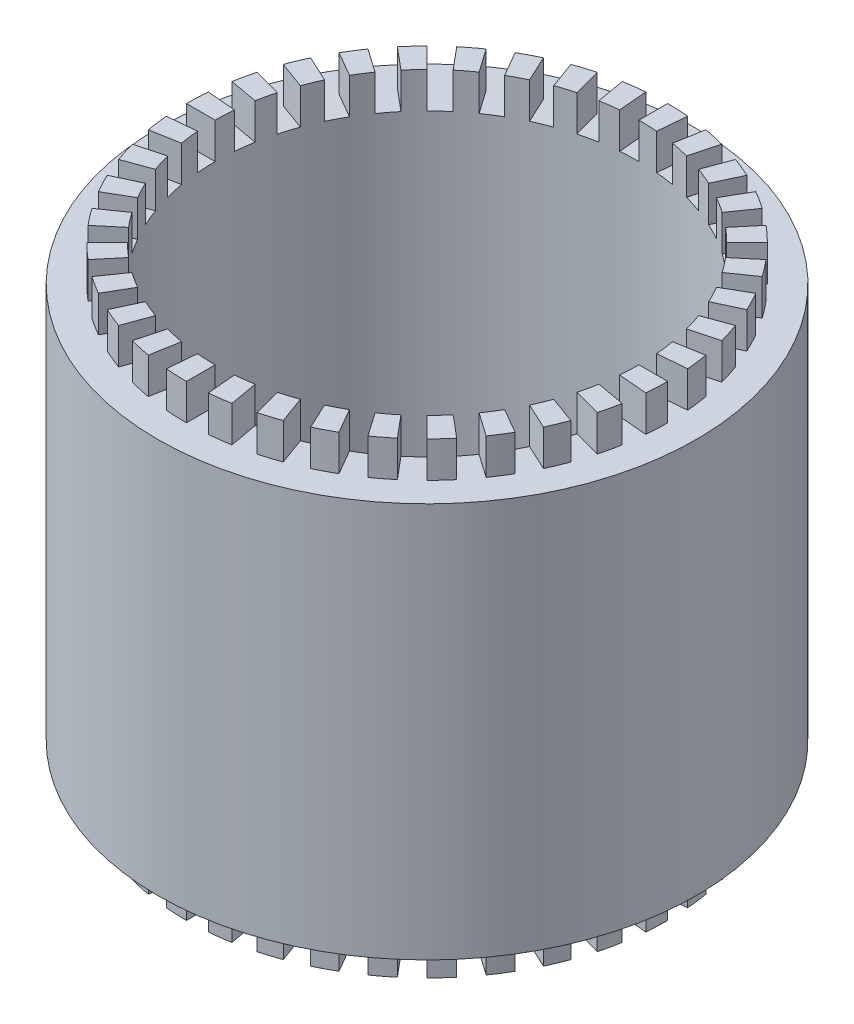
from build123d import *

# Parameters (mm, degrees)
SKETCH1_R           = 37.5
SKETCH1_R_2         = 29.5
BOSS_EXTRUDE1_DEPTH = 55
SKETCH2_R           = 33.5
SKETCH2_R_2         = 29.5
BOSS_EXTRUDE2_DEPTH = 5
SKETCH3_R           = 33.5
SKETCH3_R_2         = 29.5
BOSS_EXTRUDE3_DEPTH = 5
CUT_EXTRUDE1_DEPTH  = 5
CUT_EXTRUDE2_DEPTH  = 5


with BuildPart() as part:
    # Sketch1 → Boss-Extrude1 (new body)
    with BuildSketch(Plane(origin=(0, 0, 0), x_dir=(1, 0, 0), z_dir=(0, 1, 0))):
        Circle(SKETCH1_R)
        Circle(SKETCH1_R_2, mode=Mode.SUBTRACT)
    extrude(amount=BOSS_EXTRUDE1_DEPTH)

    # Sketch2 → Boss-Extrude2 (add)
    with BuildSketch(Plane(origin=(0, 55, 0), x_dir=(1, 0, 0), z_dir=(0, 1, 0))):
        Circle(SKETCH2_R)
        Circle(SKETCH2_R_2, mode=Mode.SUBTRACT)
    extrude(amount=BOSS_EXTRUDE2_DEPTH)

    # Sketch3 → Boss-Extrude3 (add)
    with BuildSketch(Plane.XZ):
        Circle(SKETCH3_R)
        Circle(SKETCH3_R_2, mode=Mode.SUBTRACT)
    extrude(amount=BOSS_EXTRUDE3_DEPTH)

    # Sketch4 → Cut-Extrude1 (cut)
    with BuildSketch(Plane.XZ.offset(5)):
        with BuildLine():
            Line((0, 29.5), (0, 33.5))
            ThreePointArc((0, 33.5), (1.461249477, 33.468115423), (2.919717382, 33.372522386))
            Line((2.919717382, 33.372522386), (2.571094411, 29.387743594))
            ThreePointArc((2.571094411, 29.387743594), (1.286771927, 29.471922537), (0, 29.5))
        make_face()
        with BuildLine():
            Line((5.122621241, 29.051828714), (5.817213952, 32.991059726))
            ThreePointArc((5.817213952, 32.991059726), (7.250727067, 32.705916239), (8.670438011, 32.358515181))
            Line((8.670438011, 32.358515181), (7.635161831, 28.494811876))
            ThreePointArc((7.635161831, 28.494811876), (6.384968611, 28.80073221), (5.122621241, 29.051828714))
        make_face()
        with BuildLine():
            Line((10.089594228, 27.720932313), (11.457674801, 31.479702796))
            ThreePointArc((11.457674801, 31.479702796), (12.819894984, 30.949964339), (14.157711768, 30.361310866))
            Line((14.157711768, 30.361310866), (12.467238721, 26.736079718))
            ThreePointArc((12.467238721, 26.736079718), (11.289161255, 27.254446209), (10.089594228, 27.720932313))
        make_face()
        with BuildLine():
            Line((14.75, 25.547749412), (16.75, 29.011851027))
            ThreePointArc((16.75, 29.011851027), (17.99953688, 28.253613435), (19.214810618, 27.441593484))
            Line((19.214810618, 27.441593484), (16.920504872, 24.164985307))
            ThreePointArc((16.920504872, 24.164985307), (15.850338446, 24.880047651), (14.75, 25.547749412))
        make_face()
        with BuildLine():
            Line((18.962234486, 22.598311072), (21.533384924, 25.662488844))
            ThreePointArc((21.533384924, 25.662488844), (22.632271955, 24.698790783), (23.68807717, 23.68807717))
            Line((23.68807717, 23.68807717), (20.859650045, 20.859650045))
            ThreePointArc((20.859650045, 20.859650045), (19.929911125, 21.749681436), (18.962234486, 22.598311072))
        make_face()
        with BuildLine():
            Line((22.598311072, 18.962234486), (25.662488844, 21.533384924))
            ThreePointArc((25.662488844, 21.533384924), (26.5773369, 20.393507872), (27.441593484, 19.214810618))
            Line((27.441593484, 19.214810618), (24.164985307, 16.920504872))
            ThreePointArc((24.164985307, 16.920504872), (23.403923539, 17.958462156), (22.598311072, 18.962234486))
        make_face()
        with BuildLine():
            Line((25.547749412, 14.75), (29.011851027, 16.75))
            ThreePointArc((29.011851027, 16.75), (29.714862911, 15.468578543), (30.361310866, 14.157711768))
            Line((30.361310866, 14.157711768), (26.736079718, 12.467238721))
            ThreePointArc((26.736079718, 12.467238721), (26.166819579, 13.62158409), (25.547749412, 14.75))
        make_face()
        with BuildLine():
            Line((27.720932313, 10.089594228), (31.479702796, 11.457674801))
            ThreePointArc((31.479702796, 11.457674801), (31.94951785, 10.073644283), (32.358515181, 8.670438011))
            Line((32.358515181, 8.670438011), (28.494811876, 7.635161831))
            ThreePointArc((28.494811876, 7.635161831), (28.134650047, 8.870821085), (27.720932313, 10.089594228))
        make_face()
        with BuildLine():
            Line((29.051828714, 5.122621241), (32.991059726, 5.817213952))
            ThreePointArc((32.991059726, 5.817213952), (33.213402856, 4.372627439), (33.372522386, 2.919717382))
            Line((33.372522386, 2.919717382), (29.387743594, 2.571094411))
            ThreePointArc((29.387743594, 2.571094411), (29.247623411, 3.85052267), (29.051828714, 5.122621241))
        make_face()
        with BuildLine():
            Line((29.5, 0), (33.5, 0))
            ThreePointArc((33.5, 0), (33.468115423, -1.461249477), (33.372522386, -2.919717382))
            Line((33.372522386, -2.919717382), (29.387743594, -2.571094411))
            ThreePointArc((29.387743594, -2.571094411), (29.471922537, -1.286771927), (29.5, 0))
        make_face()
        with BuildLine():
            Line((29.051828714, -5.122621241), (32.991059726, -5.817213952))
            ThreePointArc((32.991059726, -5.817213952), (32.705916239, -7.250727067), (32.358515181, -8.670438011))
            Line((32.358515181, -8.670438011), (28.494811876, -7.635161831))
            ThreePointArc((28.494811876, -7.635161831), (28.80073221, -6.384968611), (29.051828714, -5.122621241))
        make_face()
        with BuildLine():
            Line((27.720932313, -10.089594228), (31.479702796, -11.457674801))
            ThreePointArc((31.479702796, -11.457674801), (30.949964339, -12.819894984), (30.361310866, -14.157711768))
            Line((30.361310866, -14.157711768), (26.736079718, -12.467238721))
            ThreePointArc((26.736079718, -12.467238721), (27.254446209, -11.289161255), (27.720932313, -10.089594228))
        make_face()
        with BuildLine():
            Line((25.547749412, -14.75), (29.011851027, -16.75))
            ThreePointArc((29.011851027, -16.75), (28.253613435, -17.99953688), (27.441593484, -19.214810618))
            Line((27.441593484, -19.214810618), (24.164985307, -16.920504872))
            ThreePointArc((24.164985307, -16.920504872), (24.880047651, -15.850338446), (25.547749412, -14.75))
        make_face()
        with BuildLine():
            Line((22.598311072, -18.962234486), (25.662488844, -21.533384924))
            ThreePointArc((25.662488844, -21.533384924), (24.698790783, -22.632271955), (23.68807717, -23.68807717))
            Line((23.68807717, -23.68807717), (20.859650045, -20.859650045))
            ThreePointArc((20.859650045, -20.859650045), (21.749681436, -19.929911125), (22.598311072, -18.962234486))
        make_face()
        with BuildLine():
            Line((18.962234486, -22.598311072), (21.533384924, -25.662488844))
            ThreePointArc((21.533384924, -25.662488844), (20.393507872, -26.5773369), (19.214810618, -27.441593484))
            Line((19.214810618, -27.441593484), (16.920504872, -24.164985307))
            ThreePointArc((16.920504872, -24.164985307), (17.958462156, -23.403923539), (18.962234486, -22.598311072))
        make_face()
        with BuildLine():
            Line((14.75, -25.547749412), (16.75, -29.011851027))
            ThreePointArc((16.75, -29.011851027), (15.468578543, -29.714862911), (14.157711768, -30.361310866))
            Line((14.157711768, -30.361310866), (12.467238721, -26.736079718))
            ThreePointArc((12.467238721, -26.736079718), (13.62158409, -26.166819579), (14.75, -25.547749412))
        make_face()
        with BuildLine():
            Line((10.089594228, -27.720932313), (11.457674801, -31.479702796))
            ThreePointArc((11.457674801, -31.479702796), (10.073644283, -31.94951785), (8.670438011, -32.358515181))
            Line((8.670438011, -32.358515181), (7.635161831, -28.494811876))
            ThreePointArc((7.635161831, -28.494811876), (8.870821085, -28.134650047), (10.089594228, -27.720932313))
        make_face()
        with BuildLine():
            Line((5.122621241, -29.051828714), (5.817213952, -32.991059726))
            ThreePointArc((5.817213952, -32.991059726), (4.372627439, -33.213402856), (2.919717382, -33.372522386))
            Line((2.919717382, -33.372522386), (2.571094411, -29.387743594))
            ThreePointArc((2.571094411, -29.387743594), (3.85052267, -29.247623411), (5.122621241, -29.051828714))
        make_face()
        with BuildLine():
            Line((0, -29.5), (0, -33.5))
            ThreePointArc((0, -33.5), (-1.461249477, -33.468115423), (-2.919717382, -33.372522386))
            Line((-2.919717382, -33.372522386), (-2.571094411, -29.387743594))
            ThreePointArc((-2.571094411, -29.387743594), (-1.286771927, -29.471922537), (0, -29.5))
        make_face()
        with BuildLine():
            Line((-5.122621241, -29.051828714), (-5.817213952, -32.991059726))
            ThreePointArc((-5.817213952, -32.991059726), (-7.250727067, -32.705916239), (-8.670438011, -32.358515181))
            Line((-8.670438011, -32.358515181), (-7.635161831, -28.494811876))
            ThreePointArc((-7.635161831, -28.494811876), (-6.384968611, -28.80073221), (-5.122621241, -29.051828714))
        make_face()
        with BuildLine():
            Line((-10.089594228, -27.720932313), (-11.457674801, -31.479702796))
            ThreePointArc((-11.457674801, -31.479702796), (-12.819894984, -30.949964339), (-14.157711768, -30.361310866))
            Line((-14.157711768, -30.361310866), (-12.467238721, -26.736079718))
            ThreePointArc((-12.467238721, -26.736079718), (-11.289161255, -27.254446209), (-10.089594228, -27.720932313))
        make_face()
        with BuildLine():
            Line((-14.75, -25.547749412), (-16.75, -29.011851027))
            ThreePointArc((-16.75, -29.011851027), (-17.99953688, -28.253613435), (-19.214810618, -27.441593484))
            Line((-19.214810618, -27.441593484), (-16.920504872, -24.164985307))
            ThreePointArc((-16.920504872, -24.164985307), (-15.850338446, -24.880047651), (-14.75, -25.547749412))
        make_face()
        with BuildLine():
            Line((-18.962234486, -22.598311072), (-21.533384924, -25.662488844))
            ThreePointArc((-21.533384924, -25.662488844), (-22.632271955, -24.698790783), (-23.68807717, -23.68807717))
            Line((-23.68807717, -23.68807717), (-20.859650045, -20.859650045))
            ThreePointArc((-20.859650045, -20.859650045), (-19.929911125, -21.749681436), (-18.962234486, -22.598311072))
        make_face()
        with BuildLine():
            Line((-22.598311072, -18.962234486), (-25.662488844, -21.533384924))
            ThreePointArc((-25.662488844, -21.533384924), (-26.5773369, -20.393507872), (-27.441593484, -19.214810618))
            Line((-27.441593484, -19.214810618), (-24.164985307, -16.920504872))
            ThreePointArc((-24.164985307, -16.920504872), (-23.403923539, -17.958462156), (-22.598311072, -18.962234486))
        make_face()
        with BuildLine():
            Line((-25.547749412, -14.75), (-29.011851027, -16.75))
            ThreePointArc((-29.011851027, -16.75), (-29.714862911, -15.468578543), (-30.361310866, -14.157711768))
            Line((-30.361310866, -14.157711768), (-26.736079718, -12.467238721))
            ThreePointArc((-26.736079718, -12.467238721), (-26.166819579, -13.62158409), (-25.547749412, -14.75))
        make_face()
        with BuildLine():
            Line((-27.720932313, -10.089594228), (-31.479702796, -11.457674801))
            ThreePointArc((-31.479702796, -11.457674801), (-31.94951785, -10.073644283), (-32.358515181, -8.670438011))
            Line((-32.358515181, -8.670438011), (-28.494811876, -7.635161831))
            ThreePointArc((-28.494811876, -7.635161831), (-28.134650047, -8.870821085), (-27.720932313, -10.089594228))
        make_face()
        with BuildLine():
            Line((-29.051828714, -5.122621241), (-32.991059726, -5.817213952))
            ThreePointArc((-32.991059726, -5.817213952), (-33.213402856, -4.372627439), (-33.372522386, -2.919717382))
            Line((-33.372522386, -2.919717382), (-29.387743594, -2.571094411))
            ThreePointArc((-29.387743594, -2.571094411), (-29.247623411, -3.85052267), (-29.051828714, -5.122621241))
        make_face()
        with BuildLine():
            Line((-29.5, 0), (-33.5, 0))
            ThreePointArc((-33.5, 0), (-33.468115423, 1.461249477), (-33.372522386, 2.919717382))
            Line((-33.372522386, 2.919717382), (-29.387743594, 2.571094411))
            ThreePointArc((-29.387743594, 2.571094411), (-29.471922537, 1.286771927), (-29.5, 0))
        make_face()
        with BuildLine():
            Line((-29.051828714, 5.122621241), (-32.991059726, 5.817213952))
            ThreePointArc((-32.991059726, 5.817213952), (-32.705916239, 7.250727067), (-32.358515181, 8.670438011))
            Line((-32.358515181, 8.670438011), (-28.494811876, 7.635161831))
            ThreePointArc((-28.494811876, 7.635161831), (-28.80073221, 6.384968611), (-29.051828714, 5.122621241))
        make_face()
        with BuildLine():
            Line((-27.720932313, 10.089594228), (-31.479702796, 11.457674801))
            ThreePointArc((-31.479702796, 11.457674801), (-30.949964339, 12.819894984), (-30.361310866, 14.157711768))
            Line((-30.361310866, 14.157711768), (-26.736079718, 12.467238721))
            ThreePointArc((-26.736079718, 12.467238721), (-27.254446209, 11.289161255), (-27.720932313, 10.089594228))
        make_face()
        with BuildLine():
            Line((-25.547749412, 14.75), (-29.011851027, 16.75))
            ThreePointArc((-29.011851027, 16.75), (-28.253613435, 17.99953688), (-27.441593484, 19.214810618))
            Line((-27.441593484, 19.214810618), (-24.164985307, 16.920504872))
            ThreePointArc((-24.164985307, 16.920504872), (-24.880047651, 15.850338446), (-25.547749412, 14.75))
        make_face()
        with BuildLine():
            Line((-22.598311072, 18.962234486), (-25.662488844, 21.533384924))
            ThreePointArc((-25.662488844, 21.533384924), (-24.698790783, 22.632271955), (-23.68807717, 23.68807717))
            Line((-23.68807717, 23.68807717), (-20.859650045, 20.859650045))
            ThreePointArc((-20.859650045, 20.859650045), (-21.749681436, 19.929911125), (-22.598311072, 18.962234486))
        make_face()
        with BuildLine():
            Line((-18.962234486, 22.598311072), (-21.533384924, 25.662488844))
            ThreePointArc((-21.533384924, 25.662488844), (-20.393507872, 26.5773369), (-19.214810618, 27.441593484))
            Line((-19.214810618, 27.441593484), (-16.920504872, 24.164985307))
            ThreePointArc((-16.920504872, 24.164985307), (-17.958462156, 23.403923539), (-18.962234486, 22.598311072))
        make_face()
        with BuildLine():
            Line((-14.75, 25.547749412), (-16.75, 29.011851027))
            ThreePointArc((-16.75, 29.011851027), (-15.468578543, 29.714862911), (-14.157711768, 30.361310866))
            Line((-14.157711768, 30.361310866), (-12.467238721, 26.736079718))
            ThreePointArc((-12.467238721, 26.736079718), (-13.62158409, 26.166819579), (-14.75, 25.547749412))
        make_face()
        with BuildLine():
            Line((-10.089594228, 27.720932313), (-11.457674801, 31.479702796))
            ThreePointArc((-11.457674801, 31.479702796), (-10.073644283, 31.94951785), (-8.670438011, 32.358515181))
            Line((-8.670438011, 32.358515181), (-7.635161831, 28.494811876))
            ThreePointArc((-7.635161831, 28.494811876), (-8.870821085, 28.134650047), (-10.089594228, 27.720932313))
        make_face()
        with BuildLine():
            Line((-5.122621241, 29.051828714), (-5.817213952, 32.991059726))
            ThreePointArc((-5.817213952, 32.991059726), (-4.372627439, 33.213402856), (-2.919717382, 33.372522386))
            Line((-2.919717382, 33.372522386), (-2.571094411, 29.387743594))
            ThreePointArc((-2.571094411, 29.387743594), (-3.85052267, 29.247623411), (-5.122621241, 29.051828714))
        make_face()
    extrude(amount=-CUT_EXTRUDE1_DEPTH, mode=Mode.SUBTRACT)

    # Sketch5 → Cut-Extrude2 (cut)
    with BuildSketch(Plane(origin=(0, 60, 0), x_dir=(1, 0, 0), z_dir=(0, 1, 0))):
        with BuildLine():
            Line((0, -29.5), (0, -33.5))
            ThreePointArc((0, -33.5), (1.461249477, -33.468115423), (2.919717382, -33.372522386))
            Line((2.919717382, -33.372522386), (2.571094411, -29.387743594))
            ThreePointArc((2.571094411, -29.387743594), (1.286771927, -29.471922537), (0, -29.5))
        make_face()
        with BuildLine():
            Line((-5.122621241, -29.051828714), (-5.817213952, -32.991059726))
            ThreePointArc((-5.817213952, -32.991059726), (-4.372627439, -33.213402856), (-2.919717382, -33.372522386))
            Line((-2.919717382, -33.372522386), (-2.571094411, -29.387743594))
            ThreePointArc((-2.571094411, -29.387743594), (-3.85052267, -29.247623411), (-5.122621241, -29.051828714))
        make_face()
        with BuildLine():
            Line((-10.089594228, -27.720932313), (-11.457674801, -31.479702796))
            ThreePointArc((-11.457674801, -31.479702796), (-10.073644283, -31.94951785), (-8.670438011, -32.358515181))
            Line((-8.670438011, -32.358515181), (-7.635161831, -28.494811876))
            ThreePointArc((-7.635161831, -28.494811876), (-8.870821085, -28.134650047), (-10.089594228, -27.720932313))
        make_face()
        with BuildLine():
            Line((-14.75, -25.547749412), (-16.75, -29.011851027))
            ThreePointArc((-16.75, -29.011851027), (-15.468578543, -29.714862911), (-14.157711768, -30.361310866))
            Line((-14.157711768, -30.361310866), (-12.467238721, -26.736079718))
            ThreePointArc((-12.467238721, -26.736079718), (-13.62158409, -26.166819579), (-14.75, -25.547749412))
        make_face()
        with BuildLine():
            Line((-18.962234486, -22.598311072), (-21.533384924, -25.662488844))
            ThreePointArc((-21.533384924, -25.662488844), (-20.393507872, -26.5773369), (-19.214810618, -27.441593484))
            Line((-19.214810618, -27.441593484), (-16.920504872, -24.164985307))
            ThreePointArc((-16.920504872, -24.164985307), (-17.958462156, -23.403923539), (-18.962234486, -22.598311072))
        make_face()
        with BuildLine():
            Line((-22.598311072, -18.962234486), (-25.662488844, -21.533384924))
            ThreePointArc((-25.662488844, -21.533384924), (-24.698790783, -22.632271955), (-23.68807717, -23.68807717))
            Line((-23.68807717, -23.68807717), (-20.859650045, -20.859650045))
            ThreePointArc((-20.859650045, -20.859650045), (-21.749681436, -19.929911125), (-22.598311072, -18.962234486))
        make_face()
        with BuildLine():
            Line((-25.547749412, -14.75), (-29.011851027, -16.75))
            ThreePointArc((-29.011851027, -16.75), (-28.253613435, -17.99953688), (-27.441593484, -19.214810618))
            Line((-27.441593484, -19.214810618), (-24.164985307, -16.920504872))
            ThreePointArc((-24.164985307, -16.920504872), (-24.880047651, -15.850338446), (-25.547749412, -14.75))
        make_face()
        with BuildLine():
            Line((-27.720932313, -10.089594228), (-31.479702796, -11.457674801))
            ThreePointArc((-31.479702796, -11.457674801), (-30.949964339, -12.819894984), (-30.361310866, -14.157711768))
            Line((-30.361310866, -14.157711768), (-26.736079718, -12.467238721))
            ThreePointArc((-26.736079718, -12.467238721), (-27.254446209, -11.289161255), (-27.720932313, -10.089594228))
        make_face()
        with BuildLine():
            Line((-29.051828714, -5.122621241), (-32.991059726, -5.817213952))
            ThreePointArc((-32.991059726, -5.817213952), (-32.705916239, -7.250727067), (-32.358515181, -8.670438011))
            Line((-32.358515181, -8.670438011), (-28.494811876, -7.635161831))
            ThreePointArc((-28.494811876, -7.635161831), (-28.80073221, -6.384968611), (-29.051828714, -5.122621241))
        make_face()
        with BuildLine():
            Line((-29.5, 0), (-33.5, 0))
            ThreePointArc((-33.5, 0), (-33.468115423, -1.461249477), (-33.372522386, -2.919717382))
            Line((-33.372522386, -2.919717382), (-29.387743594, -2.571094411))
            ThreePointArc((-29.387743594, -2.571094411), (-29.471922537, -1.286771927), (-29.5, 0))
        make_face()
        with BuildLine():
            Line((-29.051828714, 5.122621241), (-32.991059726, 5.817213952))
            ThreePointArc((-32.991059726, 5.817213952), (-33.213402856, 4.372627439), (-33.372522386, 2.919717382))
            Line((-33.372522386, 2.919717382), (-29.387743594, 2.571094411))
            ThreePointArc((-29.387743594, 2.571094411), (-29.247623411, 3.85052267), (-29.051828714, 5.122621241))
        make_face()
        with BuildLine():
            Line((-27.720932313, 10.089594228), (-31.479702796, 11.457674801))
            ThreePointArc((-31.479702796, 11.457674801), (-31.94951785, 10.073644283), (-32.358515181, 8.670438011))
            Line((-32.358515181, 8.670438011), (-28.494811876, 7.635161831))
            ThreePointArc((-28.494811876, 7.635161831), (-28.134650047, 8.870821085), (-27.720932313, 10.089594228))
        make_face()
        with BuildLine():
            Line((-25.547749412, 14.75), (-29.011851027, 16.75))
            ThreePointArc((-29.011851027, 16.75), (-29.714862911, 15.468578543), (-30.361310866, 14.157711768))
            Line((-30.361310866, 14.157711768), (-26.736079718, 12.467238721))
            ThreePointArc((-26.736079718, 12.467238721), (-26.166819579, 13.62158409), (-25.547749412, 14.75))
        make_face()
        with BuildLine():
            Line((-22.598311072, 18.962234486), (-25.662488844, 21.533384924))
            ThreePointArc((-25.662488844, 21.533384924), (-26.5773369, 20.393507872), (-27.441593484, 19.214810618))
            Line((-27.441593484, 19.214810618), (-24.164985307, 16.920504872))
            ThreePointArc((-24.164985307, 16.920504872), (-23.403923539, 17.958462156), (-22.598311072, 18.962234486))
        make_face()
        with BuildLine():
            Line((-18.962234486, 22.598311072), (-21.533384924, 25.662488844))
            ThreePointArc((-21.533384924, 25.662488844), (-22.632271955, 24.698790783), (-23.68807717, 23.68807717))
            Line((-23.68807717, 23.68807717), (-20.859650045, 20.859650045))
            ThreePointArc((-20.859650045, 20.859650045), (-19.929911125, 21.749681436), (-18.962234486, 22.598311072))
        make_face()
        with BuildLine():
            Line((-14.75, 25.547749412), (-16.75, 29.011851027))
            ThreePointArc((-16.75, 29.011851027), (-17.99953688, 28.253613435), (-19.214810618, 27.441593484))
            Line((-19.214810618, 27.441593484), (-16.920504872, 24.164985307))
            ThreePointArc((-16.920504872, 24.164985307), (-15.850338446, 24.880047651), (-14.75, 25.547749412))
        make_face()
        with BuildLine():
            Line((-10.089594228, 27.720932313), (-11.457674801, 31.479702796))
            ThreePointArc((-11.457674801, 31.479702796), (-12.819894984, 30.949964339), (-14.157711768, 30.361310866))
            Line((-14.157711768, 30.361310866), (-12.467238721, 26.736079718))
            ThreePointArc((-12.467238721, 26.736079718), (-11.289161255, 27.254446209), (-10.089594228, 27.720932313))
        make_face()
        with BuildLine():
            Line((-5.122621241, 29.051828714), (-5.817213952, 32.991059726))
            ThreePointArc((-5.817213952, 32.991059726), (-7.250727067, 32.705916239), (-8.670438011, 32.358515181))
            Line((-8.670438011, 32.358515181), (-7.635161831, 28.494811876))
            ThreePointArc((-7.635161831, 28.494811876), (-6.384968611, 28.80073221), (-5.122621241, 29.051828714))
        make_face()
        with BuildLine():
            Line((0, 29.5), (0, 33.5))
            ThreePointArc((0, 33.5), (-1.461249477, 33.468115423), (-2.919717382, 33.372522386))
            Line((-2.919717382, 33.372522386), (-2.571094411, 29.387743594))
            ThreePointArc((-2.571094411, 29.387743594), (-1.286771927, 29.471922537), (0, 29.5))
        make_face()
        with BuildLine():
            Line((5.122621241, 29.051828714), (5.817213952, 32.991059726))
            ThreePointArc((5.817213952, 32.991059726), (4.372627439, 33.213402856), (2.919717382, 33.372522386))
            Line((2.919717382, 33.372522386), (2.571094411, 29.387743594))
            ThreePointArc((2.571094411, 29.387743594), (3.85052267, 29.247623411), (5.122621241, 29.051828714))
        make_face()
        with BuildLine():
            Line((10.089594228, 27.720932313), (11.457674801, 31.479702796))
            ThreePointArc((11.457674801, 31.479702796), (10.073644283, 31.94951785), (8.670438011, 32.358515181))
            Line((8.670438011, 32.358515181), (7.635161831, 28.494811876))
            ThreePointArc((7.635161831, 28.494811876), (8.870821085, 28.134650047), (10.089594228, 27.720932313))
        make_face()
        with BuildLine():
            Line((14.75, 25.547749412), (16.75, 29.011851027))
            ThreePointArc((16.75, 29.011851027), (15.468578543, 29.714862911), (14.157711768, 30.361310866))
            Line((14.157711768, 30.361310866), (12.467238721, 26.736079718))
            ThreePointArc((12.467238721, 26.736079718), (13.62158409, 26.166819579), (14.75, 25.547749412))
        make_face()
        with BuildLine():
            Line((18.962234486, 22.598311072), (21.533384924, 25.662488844))
            ThreePointArc((21.533384924, 25.662488844), (20.393507872, 26.5773369), (19.214810618, 27.441593484))
            Line((19.214810618, 27.441593484), (16.920504872, 24.164985307))
            ThreePointArc((16.920504872, 24.164985307), (17.958462156, 23.403923539), (18.962234486, 22.598311072))
        make_face()
        with BuildLine():
            Line((22.598311072, 18.962234486), (25.662488844, 21.533384924))
            ThreePointArc((25.662488844, 21.533384924), (24.698790783, 22.632271955), (23.68807717, 23.68807717))
            Line((23.68807717, 23.68807717), (20.859650045, 20.859650045))
            ThreePointArc((20.859650045, 20.859650045), (21.749681436, 19.929911125), (22.598311072, 18.962234486))
        make_face()
        with BuildLine():
            Line((25.547749412, 14.75), (29.011851027, 16.75))
            ThreePointArc((29.011851027, 16.75), (28.253613435, 17.99953688), (27.441593484, 19.214810618))
            Line((27.441593484, 19.214810618), (24.164985307, 16.920504872))
            ThreePointArc((24.164985307, 16.920504872), (24.880047651, 15.850338446), (25.547749412, 14.75))
        make_face()
        with BuildLine():
            Line((27.720932313, 10.089594228), (31.479702796, 11.457674801))
            ThreePointArc((31.479702796, 11.457674801), (30.949964339, 12.819894984), (30.361310866, 14.157711768))
            Line((30.361310866, 14.157711768), (26.736079718, 12.467238721))
            ThreePointArc((26.736079718, 12.467238721), (27.254446209, 11.289161255), (27.720932313, 10.089594228))
        make_face()
        with BuildLine():
            Line((29.051828714, 5.122621241), (32.991059726, 5.817213952))
            ThreePointArc((32.991059726, 5.817213952), (32.705916239, 7.250727067), (32.358515181, 8.670438011))
            Line((32.358515181, 8.670438011), (28.494811876, 7.635161831))
            ThreePointArc((28.494811876, 7.635161831), (28.80073221, 6.384968611), (29.051828714, 5.122621241))
        make_face()
        with BuildLine():
            Line((29.5, 0), (33.5, 0))
            ThreePointArc((33.5, 0), (33.468115423, 1.461249477), (33.372522386, 2.919717382))
            Line((33.372522386, 2.919717382), (29.387743594, 2.571094411))
            ThreePointArc((29.387743594, 2.571094411), (29.471922537, 1.286771927), (29.5, 0))
        make_face()
        with BuildLine():
            Line((29.051828714, -5.122621241), (32.991059726, -5.817213952))
            ThreePointArc((32.991059726, -5.817213952), (33.213402856, -4.372627439), (33.372522386, -2.919717382))
            Line((33.372522386, -2.919717382), (29.387743594, -2.571094411))
            ThreePointArc((29.387743594, -2.571094411), (29.247623411, -3.85052267), (29.051828714, -5.122621241))
        make_face()
        with BuildLine():
            Line((27.720932313, -10.089594228), (31.479702796, -11.457674801))
            ThreePointArc((31.479702796, -11.457674801), (31.94951785, -10.073644283), (32.358515181, -8.670438011))
            Line((32.358515181, -8.670438011), (28.494811876, -7.635161831))
            ThreePointArc((28.494811876, -7.635161831), (28.134650047, -8.870821085), (27.720932313, -10.089594228))
        make_face()
        with BuildLine():
            Line((25.547749412, -14.75), (29.011851027, -16.75))
            ThreePointArc((29.011851027, -16.75), (29.714862911, -15.468578543), (30.361310866, -14.157711768))
            Line((30.361310866, -14.157711768), (26.736079718, -12.467238721))
            ThreePointArc((26.736079718, -12.467238721), (26.166819579, -13.62158409), (25.547749412, -14.75))
        make_face()
        with BuildLine():
            Line((22.598311072, -18.962234486), (25.662488844, -21.533384924))
            ThreePointArc((25.662488844, -21.533384924), (26.5773369, -20.393507872), (27.441593484, -19.214810618))
            Line((27.441593484, -19.214810618), (24.164985307, -16.920504872))
            ThreePointArc((24.164985307, -16.920504872), (23.403923539, -17.958462156), (22.598311072, -18.962234486))
        make_face()
        with BuildLine():
            Line((18.962234486, -22.598311072), (21.533384924, -25.662488844))
            ThreePointArc((21.533384924, -25.662488844), (22.632271955, -24.698790783), (23.68807717, -23.68807717))
            Line((23.68807717, -23.68807717), (20.859650045, -20.859650045))
            ThreePointArc((20.859650045, -20.859650045), (19.929911125, -21.749681436), (18.962234486, -22.598311072))
        make_face()
        with BuildLine():
            Line((14.75, -25.547749412), (16.75, -29.011851027))
            ThreePointArc((16.75, -29.011851027), (17.99953688, -28.253613435), (19.214810618, -27.441593484))
            Line((19.214810618, -27.441593484), (16.920504872, -24.164985307))
            ThreePointArc((16.920504872, -24.164985307), (15.850338446, -24.880047651), (14.75, -25.547749412))
        make_face()
        with BuildLine():
            Line((10.089594228, -27.720932313), (11.457674801, -31.479702796))
            ThreePointArc((11.457674801, -31.479702796), (12.819894984, -30.949964339), (14.157711768, -30.361310866))
            Line((14.157711768, -30.361310866), (12.467238721, -26.736079718))
            ThreePointArc((12.467238721, -26.736079718), (11.289161255, -27.254446209), (10.089594228, -27.720932313))
        make_face()
        with BuildLine():
            Line((5.122621241, -29.051828714), (5.817213952, -32.991059726))
            ThreePointArc((5.817213952, -32.991059726), (7.250727067, -32.705916239), (8.670438011, -32.358515181))
            Line((8.670438011, -32.358515181), (7.635161831, -28.494811876))
            ThreePointArc((7.635161831, -28.494811876), (6.384968611, -28.80073221), (5.122621241, -29.051828714))
        make_face()
    extrude(amount=-CUT_EXTRUDE2_DEPTH, mode=Mode.SUBTRACT)


solid = part.part
